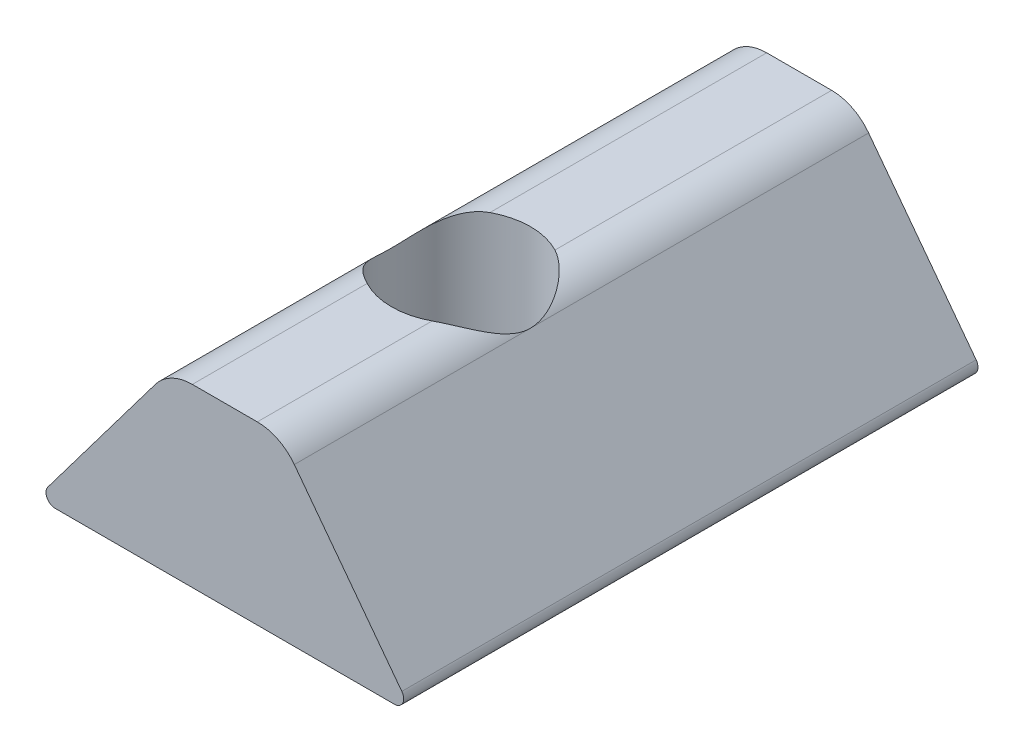
from build123d import *

# Parameters (mm, degrees)
BOSS_EXTRUDE1_DEPTH = 15.748
SKETCH2_R           = 1.905
CUT_EXTRUDE1_DEPTH  = 7.62


with BuildPart() as part:
    # Sketch1 → Boss-Extrude1 (new body)
    with BuildSketch(Plane.XY):
        with BuildLine():
            Line((-4.650037455, 0), (4.650037455, 0))
            ThreePointArc((4.650037455, 0), (4.877341219, 0.140646574), (4.852916671, 0.406826777))
            Line((4.852916671, 0.406826777), (1.905063618, 4.320133887))
            ThreePointArc((1.905063618, 4.320133887), (1.457434672, 4.692518816), (0.89066754, 4.826))
            Line((0.89066754, 4.826), (-0.89066754, 4.826))
            ThreePointArc((-0.89066754, 4.826), (-1.457434672, 4.692518816), (-1.905063618, 4.320133887))
            Line((-1.905063618, 4.320133887), (-4.852916671, 0.406826777))
            ThreePointArc((-4.852916671, 0.406826777), (-4.877341219, 0.140646574), (-4.650037455, 0))
        make_face()
    extrude(amount=-BOSS_EXTRUDE1_DEPTH)

    # Sketch2 → Cut-Extrude1 (cut)
    with BuildSketch(Plane.XZ):
        with Locations((0, -6.477)):
            Circle(SKETCH2_R)
    extrude(amount=-CUT_EXTRUDE1_DEPTH, mode=Mode.SUBTRACT)


solid = part.part
